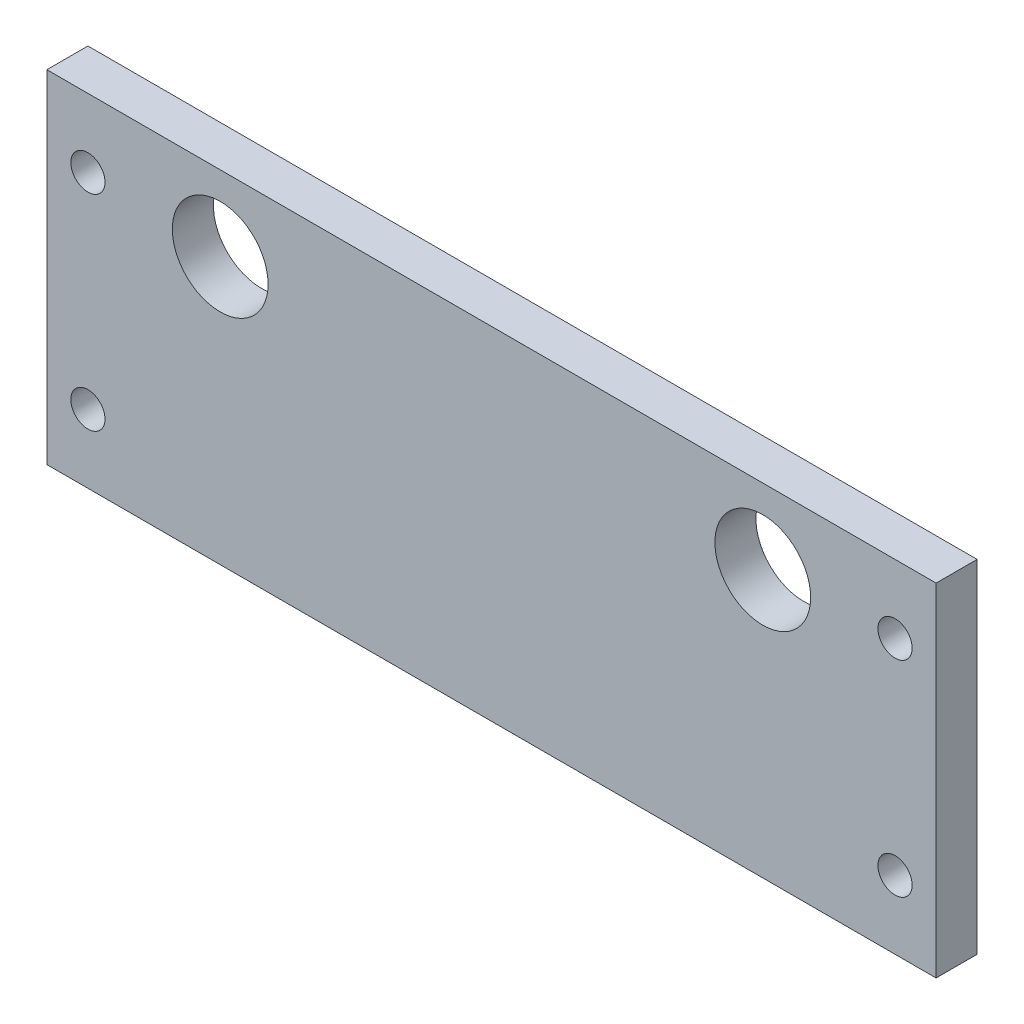
from build123d import *

# Parameters (mm, degrees)
SKETCH_1_W      = 65
SKETCH_1_H      = 25
SKETCH_1_R      = 3.5
EXTRUDE_1_DEPTH = 3
M3X0_5_1_D      = 2.5
M3X0_5_1_DEPTH  = 8.5
M3X0_5_1_TIP    = 0.751075774


with BuildPart() as part:
    # ｽｹｯﾁ1 → ﾎﾞｽ - 押し出し1 (new body)
    with BuildSketch(Plane.XY):
        Rectangle(SKETCH_1_W, SKETCH_1_H)
        with Locations((-19.83, 7)):
            Circle(SKETCH_1_R, mode=Mode.SUBTRACT)
        with Locations((19.83, 7)):
            Circle(SKETCH_1_R, mode=Mode.SUBTRACT)
    extrude(amount=EXTRUDE_1_DEPTH)

    # M3x0.5 ねじ穴1
    with Locations(Plane(origin=(-29.5, 7.5, 3), x_dir=(1, 0, 0), z_dir=(0, 0, 1))):
        with Locations((0, 0), (0, -15), (59, 0), (59, -15)):
            Hole(M3X0_5_1_D / 2, depth=M3X0_5_1_DEPTH)
            with Locations((0, 0, -(M3X0_5_1_DEPTH + M3X0_5_1_TIP / 2))):  # 118° drill point
                Cone(0, M3X0_5_1_D / 2, M3X0_5_1_TIP, mode=Mode.SUBTRACT)


solid = part.part
